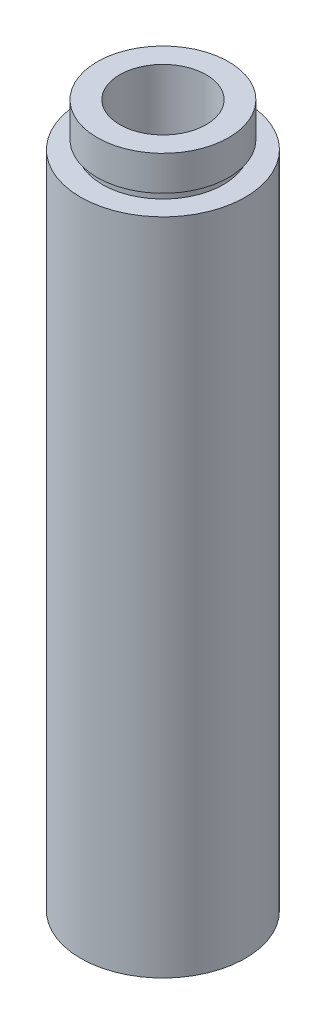
from build123d import *


with BuildPart() as part:
    # 草图1 → 旋转1 (revolve)
    with BuildSketch(Plane.XY, mode=Mode.PRIVATE) as revolve_1_sk:
        Polygon((7, 0), (7, 4.5), (7.6, 4.5), (7.6, 5.5), (5, 5.5), (5, 81.2), (7.6, 81.2), (7.6, 77.2), (7, 77.2), (7, 76.2), (9.525, 76.2), (9.525, 0), align=None)
    revolve(revolve_1_sk.sketch.rotate(Axis((0, 161.376166943, 0), (0, -1, 0)), 90), axis=Axis((0, 161.376166943, 0), (0, -1, 0)))  # turned: the seam where the file's is


solid = part.part
